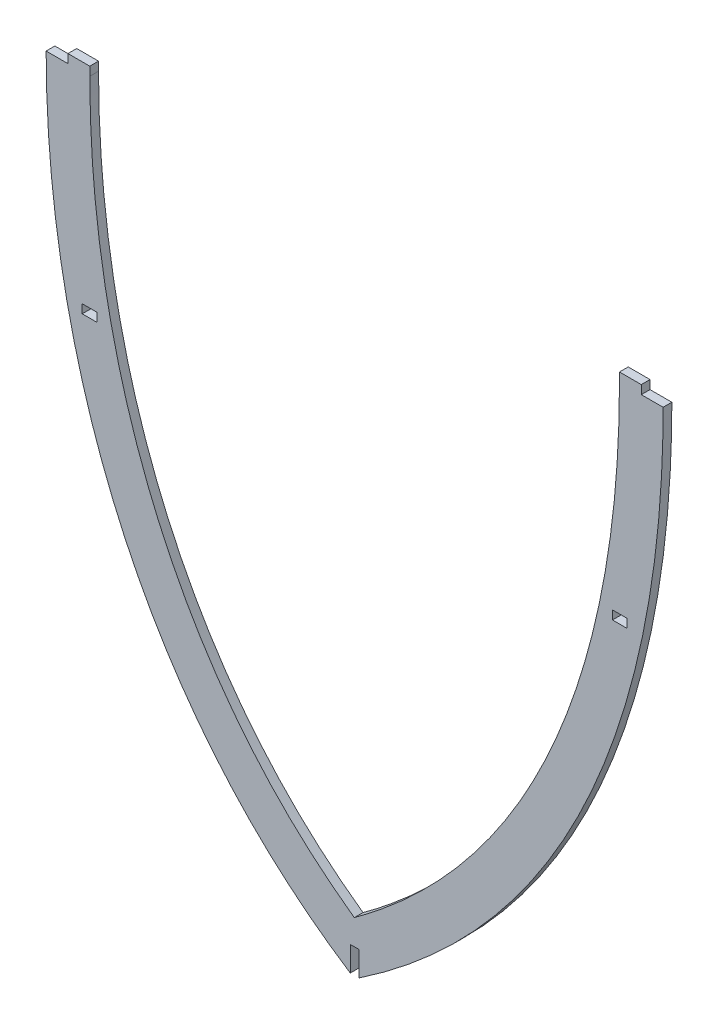
from build123d import *

# Parameters (mm, degrees)
SKETCH1_W           = 5
SKETCH1_H           = 3
BOSS_EXTRUDE1_DEPTH = 1.5
SKETCH2_W           = 3
SKETCH2_H           = 9.494035225
CUT_EXTRUDE1_DEPTH  = 3


with BuildPart() as part:
    # Sketch1 → Boss-Extrude1 (new body, symmetric)
    with BuildSketch(Plane.XY):
        with BuildLine():
            Line((-106, -83), (-98.5, -83))
            Line((-98.5, -83), (-98.5, -80))
            Line((-98.5, -80), (-91, -80))
            Line((-91, -80), (-91, -83))
            add(Edge.make_bspline(
                [(-91, -83), (-91, -88.068550738), (-90.784224976, -98.220481237), (-89.47168793, -118.377767283), (-86.146815138, -143.230800288), (-79.368059247, -172.071120857), (-69.71738881, -199.531988744), (-57.11831244, -225.231718508), (-44.09611353, -244.888891231), (-32.112008882, -259.401886537), (-22.324804426, -269.642683196), (-13.481107719, -277.613388782), (-5.992695326, -283.625797901), (-2.089373231, -286.521065709), (-0.116739636, -287.926353347)],
                knots=[0, 0, 0, 0, 0.059983469, 0.119966937, 0.239933875, 0.359900812, 0.47986775, 0.599834687, 0.719801625, 0.779785093, 0.839768562, 0.899752031, 0.929743765, 0.9597355, 0.9597355, 0.9597355, 0.9597355], degree=3))
            add(Edge.make_bspline(
                [(-0.116739636, -287.926353347), (1.870810321, -286.480217138), (5.811438827, -283.506382084), (13.355962702, -277.384642576), (22.257609381, -269.345287034), (32.090104581, -259.121737951), (44.109675826, -244.741072781), (57.139620096, -225.411627313), (69.725154077, -200.204558319), (79.363006417, -173.160517049), (85.009288933, -149.261906753), (88.135960803, -129.439309105), (89.796426225, -114.252560891), (90.618872692, -101.350995082), (90.945843548, -90.910045133), (91, -85.632026579), (91, -83)],
                knots=[0, 0, 0, 0, 0.030008035, 0.060016069, 0.120032138, 0.180048207, 0.240064276, 0.360096414, 0.480128553, 0.600160691, 0.720192829, 0.780208898, 0.840224967, 0.900241036, 0.930249071, 0.960257105, 0.960257105, 0.960257105, 0.960257105], degree=3))
            Line((91, -83), (91, -80))
            Line((91, -80), (98.5, -80))
            Line((98.5, -80), (98.5, -83))
            Line((98.5, -83), (106, -83))
            add(Edge.make_bspline(
                [(106, -83), (106, -174.443319162), (74.762940933, -256.782973383), (0, -306.089272366)],
                knots=[0, 0, 0, 0, 1, 1, 1, 1], degree=3))
            add(Edge.make_bspline(
                [(-106, -83), (-106, -171.171703536), (-74.762940933, -258.439171974), (0, -306.089272366)],
                knots=[0, 0, 0, 0, 1, 1, 1, 1], degree=3))
        make_face()
        with Locations((-91.1, -153.5)):
            Rectangle(SKETCH1_W, SKETCH1_H, mode=Mode.SUBTRACT)
        with Locations((91.1, -153.5)):
            Rectangle(SKETCH1_W, SKETCH1_H, mode=Mode.SUBTRACT)
    extrude(amount=BOSS_EXTRUDE1_DEPTH, both=True)

    # Sketch2 → Cut-Extrude1 (cut)
    with BuildSketch(Plane.XY.offset(1.5)):
        with Locations((0, -301.342254754)):
            Rectangle(SKETCH2_W, SKETCH2_H)
    extrude(amount=-CUT_EXTRUDE1_DEPTH, mode=Mode.SUBTRACT)


solid = part.part
